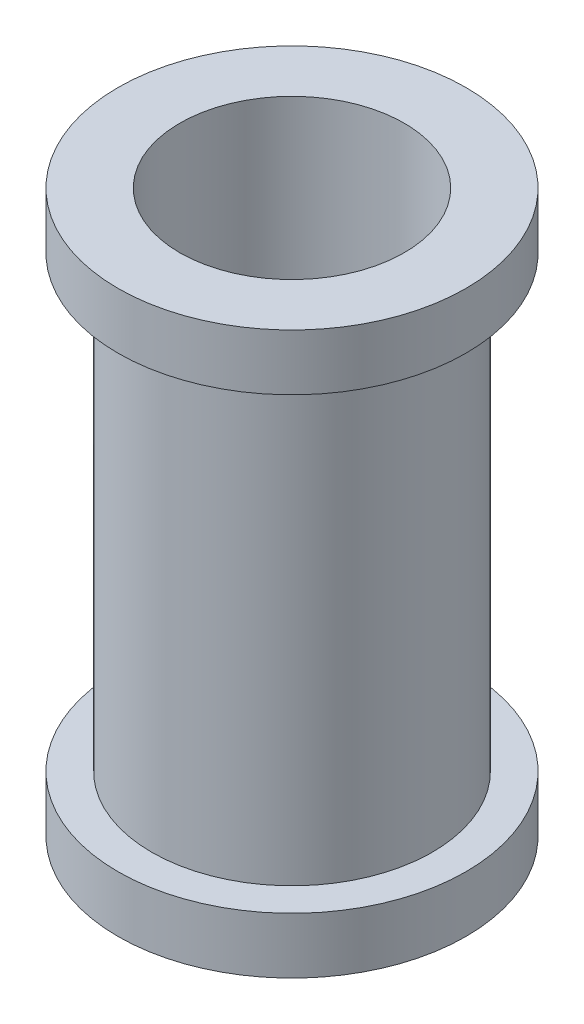
from build123d import *

# Parameters (mm, degrees)
SKETCH3_R   = 0.25
SKETCH3_R_2 = 0.2
SKETCH6_R   = 0.31
SKETCH6_R_2 = 0.21


with BuildPart() as part:
    # Sweep-Thin1: sweep along a path in Sketch1
    with BuildLine(Plane.XY) as sweep_thin1_path:
        Line((0, 0), (0, 0.5))
    # Sketch3 → Sweep-Thin1 (sweep)
    with BuildSketch(Plane(origin=(0, 0, 0), x_dir=(1, 0, 0), z_dir=(0, 1, 0))):
        Circle(SKETCH3_R)
        Circle(SKETCH3_R_2, mode=Mode.SUBTRACT)
    sweep(path=sweep_thin1_path.line)

    # Sweep-Thin2: sweep along a path in Sketch5
    with BuildLine(Plane.XY) as sweep_thin2_path:
        Line((0, 0), (0, 0.1))
    # Sketch6 → Sweep-Thin2 (sweep)
    with BuildSketch(Plane(origin=(0, 0, 0), x_dir=(1, 0, 0), z_dir=(0, 1, 0))):
        Circle(SKETCH6_R)
        Circle(SKETCH6_R_2, mode=Mode.SUBTRACT)
    sweep(path=sweep_thin2_path.line)

    # Mirror2: part across plane


with BuildPart() as part_1:
    add(part.part)
    add(part.part.mirror(Plane.ZX.offset(0.5)))


solid = part_1.part
